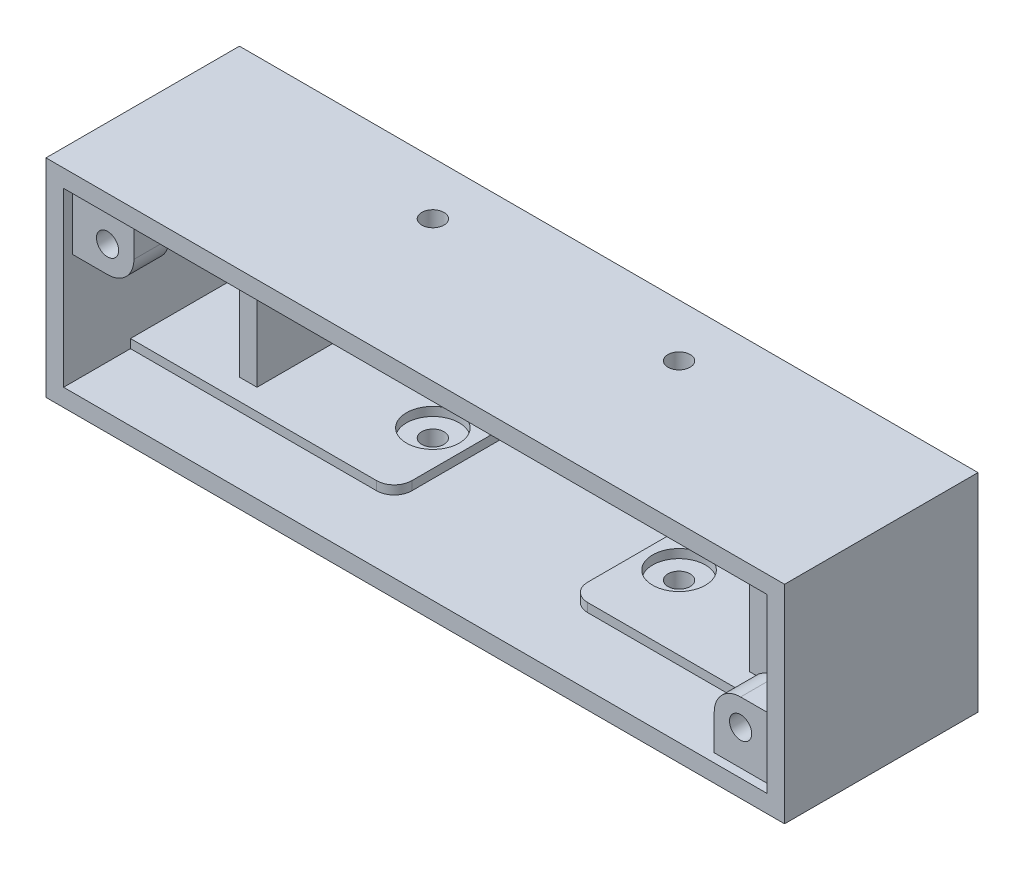
from build123d import *

# Parameters (mm, degrees)
SKETCH1_W                      = 127
SKETCH1_H                      = 31.115
BOSS_EXTRUDE1_DEPTH            = 3.175
CUT_EXTRUDE1_REACH             = 5.175
SKETCH2_R                      = 2
SKETCH2_W                      = 42
SKETCH2_H                      = 21
SKETCH3_W                      = 133.35
SKETCH3_H                      = 37.465
SKETCH3_W_2                    = 127
SKETCH3_H_2                    = 31.115
EXTRUDE_THIN1_DEPTH            = 31.75
EXTRUDE_THIN1_DEPTH_BACK       = 3.175
SKETCH4_W                      = 47.625
SKETCH4_H                      = 1.5875
BOSS_EXTRUDE2_DEPTH            = 19.67500002
CUT_EXTRUDE2_REACH             = 5.175
SKETCH6_R                      = 4.7625
BOSS_EXTRUDE4_START            = -1.5875
BOSS_EXTRUDE4_DEPTH            = 6.35
CUT_EXTRUDE3_REACH             = 36.925
SKETCH8_R                      = 2
SKETCH9_R                      = 2
CUT_EXTRUDE4_DEPTH             = 19.7325
CUT_EXTRUDE4_DEPTH_BACK        = 19.7325
SKETCH5_W                      = 3.175
SKETCH5_H                      = 27.94
BOSS_EXTRUDE3_DEPTH            = 15.875
FILLET1_R                      = 3.175
CUT_EXTRUDE5_REACH             = 20.733
SKETCH10_R                     = 4.7625
CUT_EXTRUDE5_DIRECTION_2_REACH = 20.733


with BuildPart() as part:
    # Sketch1 → Boss-Extrude1 (new body)
    with BuildSketch(Plane.XY):
        Rectangle(SKETCH1_W, SKETCH1_H)
    extrude(amount=BOSS_EXTRUDE1_DEPTH)

    # Sketch2 → Cut-Extrude1 (cut, up to next)
    with BuildSketch(Plane.XY.offset(3.175), mode=Mode.PRIVATE) as cut_extrude1_sk1:
        with Locations((-13.2, 5)):
            Circle(SKETCH2_R)
    cut_extrude1_tool1 = extrude(cut_extrude1_sk1.sketch, amount=-CUT_EXTRUDE1_REACH, mode=Mode.PRIVATE) & part.part
    add(cut_extrude1_tool1.solids().sort_by_distance((-13.2, 5, 3.175))[0], mode=Mode.SUBTRACT)
    # Sketch2 → Cut-Extrude1 (cut, up to next)
    with BuildSketch(Plane.XY.offset(3.175), mode=Mode.PRIVATE) as cut_extrude1_sk2:
        with Locations((-13.2, -5)):
            Circle(SKETCH2_R)
    cut_extrude1_tool2 = extrude(cut_extrude1_sk2.sketch, amount=-CUT_EXTRUDE1_REACH, mode=Mode.PRIVATE) & part.part
    add(cut_extrude1_tool2.solids().sort_by_distance((-13.2, -5, 3.175))[0], mode=Mode.SUBTRACT)
    # Sketch2 → Cut-Extrude1 (cut, up to next)
    with BuildSketch(Plane.XY.offset(3.175), mode=Mode.PRIVATE) as cut_extrude1_sk3:
        with Locations((35.2, 5)):
            Circle(SKETCH2_R)
    cut_extrude1_tool3 = extrude(cut_extrude1_sk3.sketch, amount=-CUT_EXTRUDE1_REACH, mode=Mode.PRIVATE) & part.part
    add(cut_extrude1_tool3.solids().sort_by_distance((35.2, 5, 3.175))[0], mode=Mode.SUBTRACT)
    # Sketch2 → Cut-Extrude1 (cut, up to next)
    with BuildSketch(Plane.XY.offset(3.175), mode=Mode.PRIVATE) as cut_extrude1_sk4:
        with Locations((35.2, -5)):
            Circle(SKETCH2_R)
    cut_extrude1_tool4 = extrude(cut_extrude1_sk4.sketch, amount=-CUT_EXTRUDE1_REACH, mode=Mode.PRIVATE) & part.part
    add(cut_extrude1_tool4.solids().sort_by_distance((35.2, -5, 3.175))[0], mode=Mode.SUBTRACT)
    # Sketch2 → Cut-Extrude1 (cut, up to next)
    with BuildSketch(Plane.XY.offset(3.175), mode=Mode.PRIVATE) as cut_extrude1_sk5:
        with Locations((11, 0)):
            Rectangle(SKETCH2_W, SKETCH2_H)
    cut_extrude1_tool5 = extrude(cut_extrude1_sk5.sketch, amount=-CUT_EXTRUDE1_REACH, mode=Mode.PRIVATE) & part.part
    add(cut_extrude1_tool5.solids().sort_by_distance((11, 0, 3.175))[0], mode=Mode.SUBTRACT)

    # Sketch3 → Extrude-Thin1 (add, two sides)
    with BuildSketch(Plane.XY.offset(3.175)) as extrude_thin1_sk:
        Rectangle(SKETCH3_W, SKETCH3_H)
        Rectangle(SKETCH3_W_2, SKETCH3_H_2, mode=Mode.SUBTRACT)
    extrude(amount=EXTRUDE_THIN1_DEPTH)
    extrude(extrude_thin1_sk.sketch, amount=-EXTRUDE_THIN1_DEPTH_BACK)

    # Sketch4 → Boss-Extrude2 (add)
    with BuildSketch(Plane.XY.offset(3.175)):
        with Locations((-39.6875, -14.76375)):
            Rectangle(SKETCH4_W, SKETCH4_H)
        with Locations((39.6875, -14.76375)):
            Rectangle(SKETCH4_W, SKETCH4_H)
        with Locations((-39.6875, 14.76375)):
            Rectangle(SKETCH4_W, SKETCH4_H)
        with Locations((39.6875, 14.76375)):
            Rectangle(SKETCH4_W, SKETCH4_H)
    extrude(amount=BOSS_EXTRUDE2_DEPTH)

    # Sketch6 → Cut-Extrude2 (cut, up to next)
    with BuildSketch(Plane.XY.offset(3.175), mode=Mode.PRIVATE) as cut_extrude2_sk1:
        with Locations((-57.15, 9.2075)):
            Circle(SKETCH6_R)
    cut_extrude2_tool1 = extrude(cut_extrude2_sk1.sketch, amount=-CUT_EXTRUDE2_REACH, mode=Mode.PRIVATE) & part.part
    add(cut_extrude2_tool1.solids().sort_by_distance((-57.15, 9.2075, 3.175))[0], mode=Mode.SUBTRACT)
    # Sketch6 → Cut-Extrude2 (cut, up to next)
    with BuildSketch(Plane.XY.offset(3.175), mode=Mode.PRIVATE) as cut_extrude2_sk2:
        with Locations((57.15, -9.2075)):
            Circle(SKETCH6_R)
    cut_extrude2_tool2 = extrude(cut_extrude2_sk2.sketch, amount=-CUT_EXTRUDE2_REACH, mode=Mode.PRIVATE) & part.part
    add(cut_extrude2_tool2.solids().sort_by_distance((57.15, -9.2075, 3.175))[0], mode=Mode.SUBTRACT)

    # Sketch7 → Boss-Extrude4 (add)
    with BuildSketch(Plane.XY.offset(34.925).offset(BOSS_EXTRUDE4_START)):
        with BuildLine():
            Line((-63.5, 15.5575), (-63.5, 4.445))
            Line((-63.5, 4.445), (-57.15, 4.445))
            ThreePointArc((-57.15, 4.445), (-53.782403955, 5.839903955), (-52.3875, 9.2075))
            Line((-52.3875, 9.2075), (-52.3875, 15.5575))
            Line((-52.3875, 15.5575), (-63.5, 15.5575))
        make_face()
        with BuildLine():
            Line((63.5, -15.5575), (52.3875, -15.5575))
            Line((52.3875, -15.5575), (52.3875, -9.2075))
            ThreePointArc((52.3875, -9.2075), (53.782403955, -5.839903955), (57.15, -4.445))
            Line((57.15, -4.445), (63.5, -4.445))
            Line((63.5, -4.445), (63.5, -15.5575))
        make_face()
    extrude(amount=-BOSS_EXTRUDE4_DEPTH)

    # Sketch8 → Cut-Extrude3 (cut, up to next)
    with BuildSketch(Plane.XY.offset(34.925), mode=Mode.PRIVATE) as cut_extrude3_sk1:
        with Locations((-57.15, 9.2075)):
            Circle(SKETCH8_R)
    cut_extrude3_tool1 = extrude(cut_extrude3_sk1.sketch, amount=-CUT_EXTRUDE3_REACH, mode=Mode.PRIVATE) & part.part
    add(cut_extrude3_tool1.solids().sort_by_distance((-57.15, 9.2075, 34.925))[0], mode=Mode.SUBTRACT)
    # Sketch8 → Cut-Extrude3 (cut, up to next)
    with BuildSketch(Plane.XY.offset(34.925), mode=Mode.PRIVATE) as cut_extrude3_sk2:
        with Locations((57.15, -9.2075)):
            Circle(SKETCH8_R)
    cut_extrude3_tool2 = extrude(cut_extrude3_sk2.sketch, amount=-CUT_EXTRUDE3_REACH, mode=Mode.PRIVATE) & part.part
    add(cut_extrude3_tool2.solids().sort_by_distance((57.15, -9.2075, 34.925))[0], mode=Mode.SUBTRACT)

    # Sketch9 → Cut-Extrude4 (cut, two sides)
    with BuildSketch(Plane(origin=(0, 0, 0), x_dir=(1, 0, 0), z_dir=(0, 1, 0))) as cut_extrude4_sk:
        with Locations((22.225, -9.525)):
            Circle(SKETCH9_R)
        with Locations((-22.225, -9.525)):
            Circle(SKETCH9_R)
    extrude(amount=CUT_EXTRUDE4_DEPTH, mode=Mode.SUBTRACT)
    extrude(cut_extrude4_sk.sketch, amount=-CUT_EXTRUDE4_DEPTH_BACK, mode=Mode.SUBTRACT)

    # Sketch5 → Boss-Extrude3 (add)
    with BuildSketch(Plane.XY.offset(3.175)):
        with Locations((46.0375, 0)):
            Rectangle(SKETCH5_W, SKETCH5_H)
        with Locations((-46.0375, 0)):
            Rectangle(SKETCH5_W, SKETCH5_H)
    extrude(amount=BOSS_EXTRUDE3_DEPTH)

    # Fillet1
    fillet1_edges = [part.edges().sort_by_distance(p)[0] for p in [
        (15.875, 14.76375, 22.85000002),
        (-15.875, -14.76375, 22.85000002),
        (15.875, -14.76375, 22.85000002),
        (-15.875, 14.76375, 22.85000002),
    ]]
    fillet(fillet1_edges, radius=FILLET1_R)

    # Cut-Extrude5: up to this face of the body (flat: up to its plane)
    cut_extrude5_end = Plane(part.part.faces().sort_by_distance((-1.954505757, -15.5575, 24.090116644))[0])
    # Sketch10 → Cut-Extrude5 (cut, up to the picked face)
    with BuildSketch(Plane(origin=(0, 0, 0), x_dir=(1, 0, 0), z_dir=(0, 1, 0)), mode=Mode.PRIVATE) as cut_extrude5_sk1:
        with Locations((-22.225, -9.525)):
            Circle(SKETCH10_R)
    cut_extrude5_tool1 = split(extrude(cut_extrude5_sk1.sketch, amount=-CUT_EXTRUDE5_REACH, mode=Mode.PRIVATE), bisect_by=cut_extrude5_end, keep=Keep.BOTH, mode=Mode.PRIVATE)
    add(cut_extrude5_tool1.solids().sort_by_distance((-22.225, 0, 9.525))[0], mode=Mode.SUBTRACT)
    # Sketch10 → Cut-Extrude5 (cut, up to the picked face)
    with BuildSketch(Plane(origin=(0, 0, 0), x_dir=(1, 0, 0), z_dir=(0, 1, 0)), mode=Mode.PRIVATE) as cut_extrude5_sk2:
        with Locations((22.225, -9.525)):
            Circle(SKETCH10_R)
    cut_extrude5_tool2 = split(extrude(cut_extrude5_sk2.sketch, amount=-CUT_EXTRUDE5_REACH, mode=Mode.PRIVATE), bisect_by=cut_extrude5_end, keep=Keep.BOTH, mode=Mode.PRIVATE)
    add(cut_extrude5_tool2.solids().sort_by_distance((22.225, 0, 9.525))[0], mode=Mode.SUBTRACT)

    # Cut-Extrude5 direction 2: up to this face of the body (flat: up to its plane)
    cut_extrude5_direction_2_end = Plane(part.part.faces().sort_by_distance((1.954505757, 15.5575, 24.090116644))[0])
    # Sketch10 → Cut-Extrude5 direction 2 (cut, up to the picked face)
    with BuildSketch(Plane(origin=(0, 0, 0), x_dir=(1, 0, 0), z_dir=(0, 1, 0)), mode=Mode.PRIVATE) as cut_extrude5_direction_2_sk1:
        with Locations((-22.225, -9.525)):
            Circle(SKETCH10_R)
    cut_extrude5_direction_2_tool1 = split(extrude(cut_extrude5_direction_2_sk1.sketch, amount=CUT_EXTRUDE5_DIRECTION_2_REACH, mode=Mode.PRIVATE), bisect_by=cut_extrude5_direction_2_end, keep=Keep.BOTH, mode=Mode.PRIVATE)
    add(cut_extrude5_direction_2_tool1.solids().sort_by_distance((-22.225, 0, 9.525))[0], mode=Mode.SUBTRACT)
    # Sketch10 → Cut-Extrude5 direction 2 (cut, up to the picked face)
    with BuildSketch(Plane(origin=(0, 0, 0), x_dir=(1, 0, 0), z_dir=(0, 1, 0)), mode=Mode.PRIVATE) as cut_extrude5_direction_2_sk2:
        with Locations((22.225, -9.525)):
            Circle(SKETCH10_R)
    cut_extrude5_direction_2_tool2 = split(extrude(cut_extrude5_direction_2_sk2.sketch, amount=CUT_EXTRUDE5_DIRECTION_2_REACH, mode=Mode.PRIVATE), bisect_by=cut_extrude5_direction_2_end, keep=Keep.BOTH, mode=Mode.PRIVATE)
    add(cut_extrude5_direction_2_tool2.solids().sort_by_distance((22.225, 0, 9.525))[0], mode=Mode.SUBTRACT)


solid = part.part
